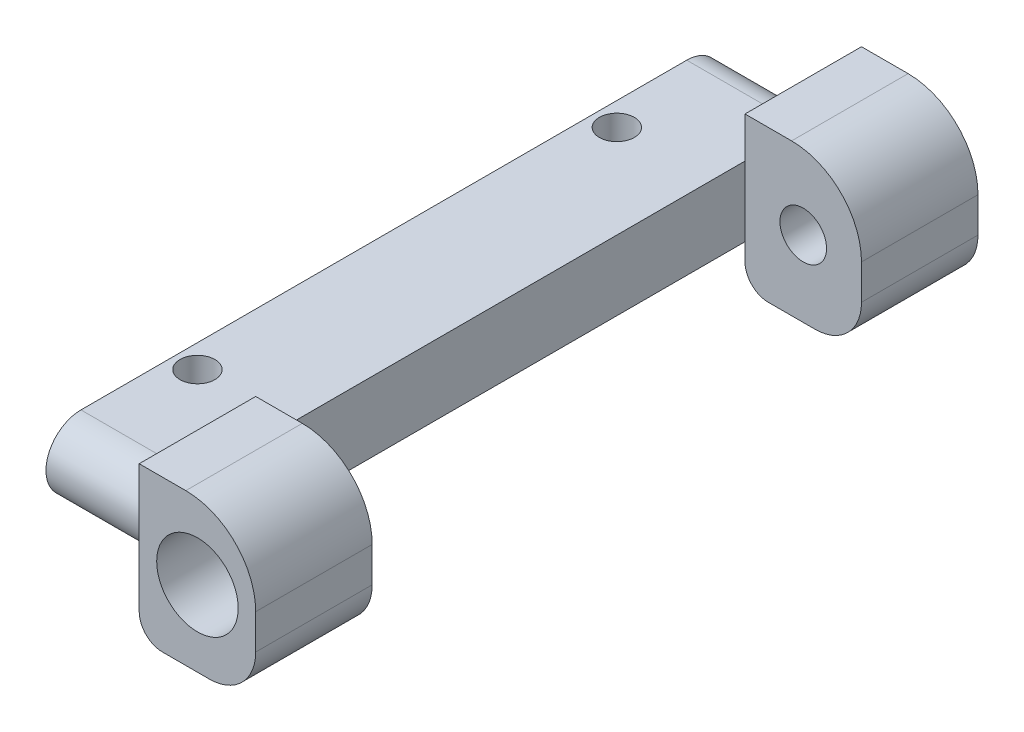
from build123d import *

# Parameters (mm, degrees)
SALIENTE_EXTRUIR1_DEPTH = 5
CROQUIS2_W              = 5
CROQUIS2_H              = 6.5
SALIENTE_EXTRUIR3_DEPTH = 5
REDONDEO1_R             = 3
REDONDEO2_R             = 2
REDONDEO3_R             = 1
CROQUIS4_R              = 1.75
CORTAR_EXTRUIR1_DEPTH   = 2.5
CROQUIS5_R              = 1
CORTAR_EXTRUIR2_DEPTH   = 2.5
CROQUIS6_R              = 0.75
CORTAR_EXTRUIR3_DEPTH   = 5


with BuildPart() as part:
    # Croquis1 → Saliente-Extruir1 (new body)
    with BuildSketch(Plane(origin=(0, 0, 0), x_dir=(0, 0, -1), z_dir=(1, 0, 0))):
        with BuildLine():
            Line((-13, 1.5), (13, 1.5))
            ThreePointArc((13, 1.5), (14.5, 0), (13, -1.5))
            Line((13, -1.5), (-13, -1.5))
            ThreePointArc((-13, -1.5), (-14.5, 0), (-13, 1.5))
        make_face()
    extrude(amount=SALIENTE_EXTRUIR1_DEPTH)

    # Croquis2 → Saliente-Extruir3 (add)
    with BuildSketch(Plane(origin=(5, 0, 0), x_dir=(0, 0, -1), z_dir=(1, 0, 0))):
        with Locations((-13, 0)):
            Rectangle(CROQUIS2_W, CROQUIS2_H)
        with Locations((13, 0)):
            Rectangle(CROQUIS2_W, CROQUIS2_H)
    extrude(amount=SALIENTE_EXTRUIR3_DEPTH)

    # Redondeo1
    redondeo1_edges = [part.edges().sort_by_distance(p)[0] for p in [
        (10, 3.25, 13),
        (10, 3.25, -13),
    ]]
    fillet(redondeo1_edges, radius=REDONDEO1_R)

    # Redondeo2
    redondeo2_edges = [part.edges().sort_by_distance(p)[0] for p in [
        (10, -3.25, 13),
        (10, -3.25, -13),
    ]]
    fillet(redondeo2_edges, radius=REDONDEO2_R)

    # Redondeo3
    redondeo3_edges = [part.edges().sort_by_distance(p)[0] for p in [
        (5, -3.25, 13),
        (5, -3.25, -13),
    ]]
    fillet(redondeo3_edges, radius=REDONDEO3_R)

    # Croquis4 → Cortar-Extruir1 (cut)
    with BuildSketch(Plane(origin=(0, 0, -15.5), x_dir=(-1, 0, 0), z_dir=(0, 0, -1))):
        with Locations((-7.5, 0)):
            Circle(CROQUIS4_R)
    cortar_extruir1 = extrude(amount=-CORTAR_EXTRUIR1_DEPTH, mode=Mode.SUBTRACT)

    # Croquis5 → Cortar-Extruir2 (cut)
    with BuildSketch(Plane(origin=(0, 0, -13), x_dir=(-1, 0, 0), z_dir=(0, 0, -1))):
        with Locations((-7.5, 0)):
            Circle(CROQUIS5_R)
    cortar_extruir2 = extrude(amount=-CORTAR_EXTRUIR2_DEPTH, mode=Mode.SUBTRACT)

    # Simetría2: Cortar-Extruir1, Cortar-Extruir2 across plane
    add(cortar_extruir1.mirror(Plane.XY), mode=Mode.SUBTRACT)
    add(cortar_extruir2.mirror(Plane.XY), mode=Mode.SUBTRACT)

    # Croquis6 → Cortar-Extruir3 (cut)
    with BuildSketch(Plane(origin=(0, 1.5, 0), x_dir=(1, 0, 0), z_dir=(0, 1, 0))):
        with Locations((1, 9)):
            Circle(CROQUIS6_R)
        with Locations((1, -9)):
            Circle(CROQUIS6_R)
    extrude(amount=-CORTAR_EXTRUIR3_DEPTH, mode=Mode.SUBTRACT)


solid = part.part
